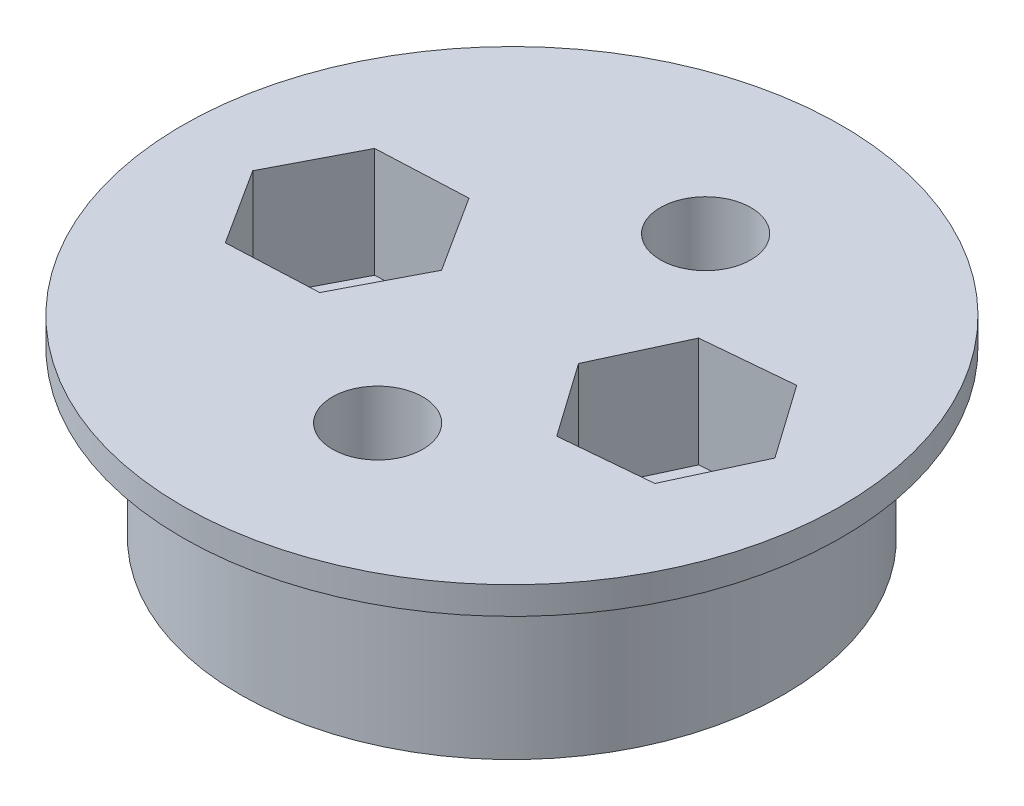
from build123d import *

# Parameters (mm, degrees)
SKETCH1_R           = 9.9
BOSS_EXTRUDE1_DEPTH = 7
SKETCH1_3_R         = 12
BOSS_EXTRUDE2_DEPTH = 1
SKETCH1_4_R         = 1.65
CUT_EXTRUDE1_DEPTH  = 11
CUT_EXTRUDE2_DEPTH  = 4


with BuildPart() as part:
    # Sketch1 → Boss-Extrude1 (new body)
    with BuildSketch(Plane(origin=(0, 0, 0), x_dir=(1, 0, 0), z_dir=(0, 1, 0))):
        with Locations((-1.873325665, 1.210998997)):
            Circle(SKETCH1_R)
    extrude(amount=-BOSS_EXTRUDE1_DEPTH)

    # Sketch1_3 → Boss-Extrude2 (add)
    with BuildSketch(Plane(origin=(0, 0, 0), x_dir=(1, 0, 0), z_dir=(0, 1, 0))):
        with Locations((-1.873325665, 1.210998997)):
            Circle(SKETCH1_3_R)
    extrude(amount=-BOSS_EXTRUDE2_DEPTH)

    # Sketch1_4 → Cut-Extrude1 (cut)
    with BuildSketch(Plane(origin=(0, 0, 0), x_dir=(1, 0, 0), z_dir=(0, 1, 0))):
        with Locations((-0.93043169, 7.320486504)):
            Circle(SKETCH1_4_R)
        with Locations((-0.93043169, -4.621555184)):
            Circle(SKETCH1_4_R)
        with Locations((-7.873325665, 1.210998997)):
            Circle(SKETCH1_4_R)
        with Locations((4.126674335, 1.210998997)):
            Circle(SKETCH1_4_R)
    extrude(amount=-CUT_EXTRUDE1_DEPTH, mode=Mode.SUBTRACT)

    # Sketch1_5 → Cut-Extrude2 (cut)
    with BuildSketch(Plane(origin=(0, 0, 0), x_dir=(1, 0, 0), z_dir=(0, 1, 0))):
        Polygon((-6.100068619, -1.56128516), (-4.585828635, 1.360542568), (-6.359085682, 4.132826725), (-9.646582711, 3.983283154), (-11.160822695, 1.061455426), (-9.387565648, -1.710828731), align=None)
        Polygon((6.021818673, -1.47943367), (7.404229541, 1.507025804), (5.509085203, 4.197458471), (2.231529997, 3.901431664), (0.849119129, 0.91497219), (2.744263467, -1.775460477), align=None)
    extrude(amount=-CUT_EXTRUDE2_DEPTH, mode=Mode.SUBTRACT)


solid = part.part
